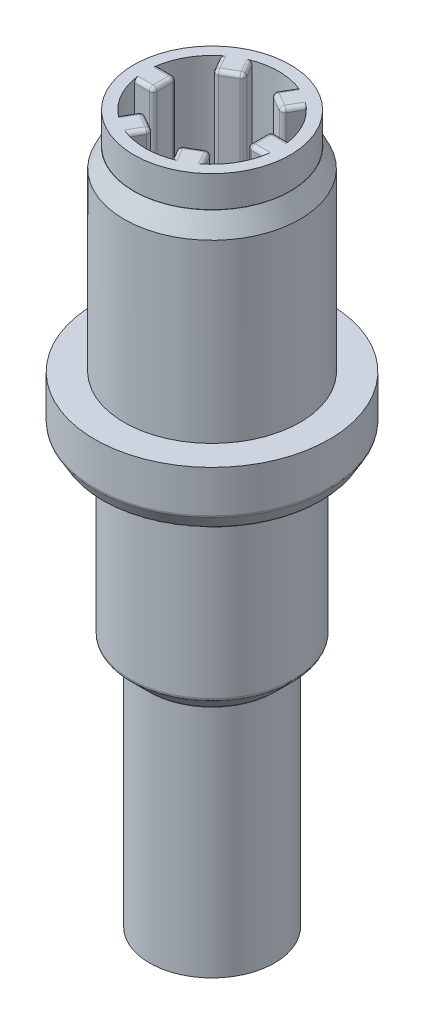
from build123d import *

# Parameters (mm, degrees)
SKETCH1_R           = 2.25
BOSS_EXTRUDE1_DEPTH = 5
SKETCH2_R           = 3
BOSS_EXTRUDE2_DEPTH = 1.5
CHAMFER1_SIZE       = 0.4
CHAMFER1_SIZE2      = 0.230940108
FILLET1_R           = 0.1
SKETCH3_R           = 2.1
BOSS_EXTRUDE3_DEPTH = 4.8
CHAMFER2_SIZE       = 0.5
FILLET2_R           = 0.1
SKETCH4_R           = 1.6
BOSS_EXTRUDE4_DEPTH = 6
SKETCH5_R           = 2
BOSS_EXTRUDE5_DEPTH = 0.8
CHAMFER3_SIZE       = 0.5
CHAMFER3_SIZE2      = 0.243866294
CUT_EXTRUDE3_START  = -11.629289
SKETCH6_R           = 1.706133706
CUT_EXTRUDE3_DEPTH  = 11.629289
SKETCH7_W           = 0.634931808
SKETCH7_H           = 0.6
BOSS_EXTRUDE6_DEPTH = 11.329289
CIRPATTERN2_COUNT   = 6
FILLET3_R           = 0.1
FILLET4_R           = 0.1
CUT_EXTRUDE4_REACH  = 20.1
SKETCH8_R           = 1.2446


with BuildPart() as part:
    # Sketch1 → Boss-Extrude1 (new body)
    with BuildSketch(Plane(origin=(0, 0, 0), x_dir=(1, 0, 0), z_dir=(0, 1, 0))):
        with Locations(Location((0, 0, 0), (0, 0, 270))):  # turned: the seam where the file's is
            Circle(SKETCH1_R)
    extrude(amount=BOSS_EXTRUDE1_DEPTH)

    # Sketch2 → Boss-Extrude2 (add)
    with BuildSketch(Plane(origin=(0, 0, 0), x_dir=(-1, 0, 0), z_dir=(0, -1, 0))):
        with Locations(Location((0, 0, 0), (0, 0, 90))):  # turned: the seam where the file's is
            Circle(SKETCH2_R)
    extrude(amount=BOSS_EXTRUDE2_DEPTH)

    # Chamfer1
    chamfer1_edges = [part.edges().sort_by_distance(p)[0] for p in [
        (0, -1.5, 3),
    ]]
    chamfer1_side = [part.faces().sort_by_distance(p)[0] for p in [
        (0, -0.75, 3),
    ]]
    chamfer(chamfer1_edges, length=CHAMFER1_SIZE, length2=CHAMFER1_SIZE2, reference=chamfer1_side[0])

    # Fillet1
    fillet1_edges = [part.edges().sort_by_distance(p)[0] for p in [
        (0, -1.1, 3),
        (0, -1.5, 2.769059892),
    ]]
    fillet(fillet1_edges, radius=FILLET1_R)

    # Sketch3 → Boss-Extrude3 (add)
    with BuildSketch(Plane(origin=(0, -1.5, 0), x_dir=(-1, 0, 0), z_dir=(0, -1, 0))):
        with Locations(Location((0, 0, 0), (0, 0, 90))):  # turned: the seam where the file's is
            Circle(SKETCH3_R)
    extrude(amount=BOSS_EXTRUDE3_DEPTH)

    # Chamfer2
    chamfer2_edges = [part.edges().sort_by_distance(p)[0] for p in [
        (0, -6.3, 2.1),
    ]]
    chamfer(chamfer2_edges, length=CHAMFER2_SIZE)

    # Fillet2
    fillet2_edges = [part.edges().sort_by_distance(p)[0] for p in [
        (0, -6.3, 1.6),
        (0, -5.8, 2.1),
    ]]
    fillet(fillet2_edges, radius=FILLET2_R)

    # Sketch4 → Boss-Extrude4 (add)
    with BuildSketch(Plane(origin=(0, -6.3, 0), x_dir=(-1, 0, 0), z_dir=(0, -1, 0))):
        with Locations(Location((0, 0, 0), (0, 0, 90))):  # turned: the seam where the file's is
            Circle(SKETCH4_R)
    extrude(amount=BOSS_EXTRUDE4_DEPTH)

    # Sketch5 → Boss-Extrude5 (add)
    with BuildSketch(Plane(origin=(0, 5, 0), x_dir=(1, 0, 0), z_dir=(0, 1, 0))):
        with Locations(Location((0, 0, 0), (0, 0, 270))):  # turned: the seam where the file's is
            Circle(SKETCH5_R)
    extrude(amount=BOSS_EXTRUDE5_DEPTH)

    # Chamfer3
    chamfer3_edges = [part.edges().sort_by_distance(p)[0] for p in [
        (0, 5, -2.25),
    ]]
    chamfer3_side = [part.faces().sort_by_distance(p)[0] for p in [
        (0, 2.5, -2.25),
    ]]
    chamfer(chamfer3_edges, length=CHAMFER3_SIZE, length2=CHAMFER3_SIZE2, reference=chamfer3_side[0])

    # Sketch6 → Cut-Extrude3 (cut)
    with BuildSketch(Plane(origin=(0, 5.8, 0), x_dir=(1, 0, 0), z_dir=(0, 1, 0)).offset(CUT_EXTRUDE3_START)):
        with Locations(Location((0, 0, 0), (0, 0, 270))):  # turned: the seam where the file's is
            Circle(SKETCH6_R)
    extrude(amount=CUT_EXTRUDE3_DEPTH, mode=Mode.SUBTRACT)

    # Sketch7 → Boss-Extrude6 (add)
    with BuildSketch(Plane(origin=(0, 5.8, 0), x_dir=(1, 0, 0), z_dir=(0, 1, 0))):
        with Locations((-1.52359961, 0)):
            Rectangle(SKETCH7_W, SKETCH7_H)
    boss_extrude6 = extrude(amount=-BOSS_EXTRUDE6_DEPTH)

    # CirPattern2: Boss-Extrude6 ×6 about axis
    cirpattern2_axis = Axis((0, 0, 0), (0, 1, 0))
    for i in range(1, CIRPATTERN2_COUNT):
        add(boss_extrude6.rotate(cirpattern2_axis, i * 360 / CIRPATTERN2_COUNT))

    # Fillet3
    fillet3_edges = [part.edges().sort_by_distance(p)[0] for p in [
        (-1.206133706, 0.1353555, 0.3),
        (-1.442842451, 5.8, -0.3),
        (-1.442842451, 5.8, 0.3),
        (-1.206133706, 5.8, 0),
        (-1.206133706, 0.1353555, -0.3),
    ]]
    fillet(fillet3_edges, radius=FILLET3_R)

    # Fillet4
    fillet4_edges = [part.edges().sort_by_distance(p)[0] for p in [
        (1.206133706, 0.1353555, -0.3),
        (1.442842451, 5.8, 0.3),
        (1.442842451, 5.8, -0.3),
        (1.206133706, 5.8, 0),
        (1.206133706, 0.1353555, 0.3),
        (0.343259232, 0.1353555, -1.19454243),
        (0.981228847, 5.8, -1.099538216),
        (0.461613604, 5.8, -1.399538216),
        (0.603066853, 5.8, -1.04454243),
        (0.862874474, 0.1353555, -0.89454243),
        (-0.862874474, 0.1353555, -0.89454243),
        (-0.461613604, 5.8, -1.399538216),
        (-0.981228847, 5.8, -1.099538216),
        (-0.603066853, 5.8, -1.04454243),
        (-0.343259232, 0.1353555, -1.19454243),
        (-0.343259232, 0.1353555, 1.19454243),
        (-0.981228847, 5.8, 1.099538216),
        (-0.461613604, 5.8, 1.399538216),
        (-0.603066853, 5.8, 1.04454243),
        (-0.862874474, 0.1353555, 0.89454243),
        (0.862874474, 0.1353555, 0.89454243),
        (0.461613604, 5.8, 1.399538216),
        (0.981228847, 5.8, 1.099538216),
        (0.603066853, 5.8, 1.04454243),
        (0.343259232, 0.1353555, 1.19454243),
    ]]
    fillet(fillet4_edges, radius=FILLET4_R)

    # Sketch8 → Cut-Extrude4 (cut, up to next)
    with BuildSketch(Plane(origin=(0, -12.3, 0), x_dir=(-1, 0, 0), z_dir=(0, -1, 0)), mode=Mode.PRIVATE) as cut_extrude4_sk1:
        with Locations(Location((0, 0, 0), (0, 0, 90))):  # turned: the seam where the file's is
            Circle(SKETCH8_R)
    cut_extrude4_tool1 = extrude(cut_extrude4_sk1.sketch, amount=-CUT_EXTRUDE4_REACH, mode=Mode.PRIVATE) & part.part
    add(cut_extrude4_tool1.solids().sort_by_distance((0, -12.3, 0))[0], mode=Mode.SUBTRACT)


solid = part.part
